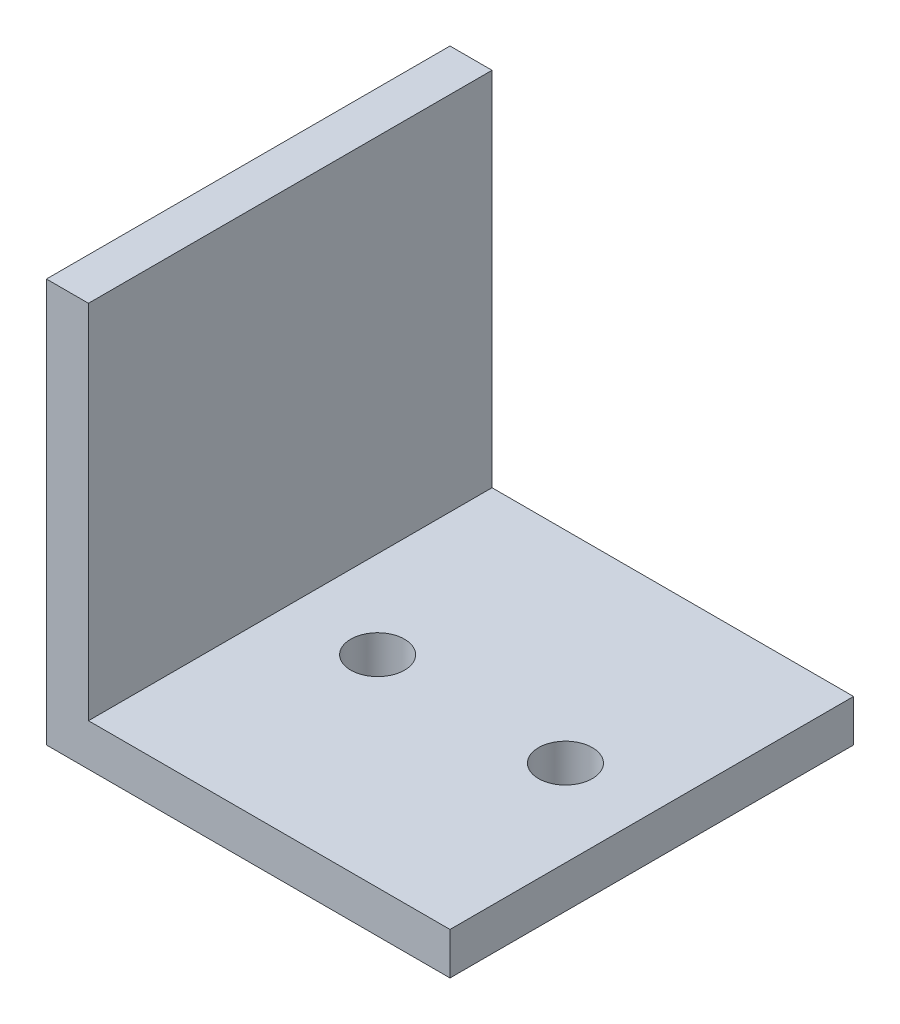
from build123d import *

# Parameters (mm, degrees)
EXTRUS_O_FINA1_DEPTH  = 30
ESBO_O2_R             = 2
CORTE_EXTRUS_O1_DEPTH = 30


with BuildPart() as part:
    # Esboço1 → Extrusão-Fina1 (new body)
    with BuildSketch(Plane.XY):
        Polygon((0, 0), (-30, 0), (-30, 30), (-26.875, 30), (-26.875, 3.125), (0, 3.125), align=None)
    extrude(amount=EXTRUS_O_FINA1_DEPTH)

    # Esboço2 → Corte-extrusão1 (cut)
    with BuildSketch(Plane(origin=(0, 3.125, 0), x_dir=(1, 0, 0), z_dir=(0, 1, 0))):
        with Locations(Location((-6.417692874, -15, 0), (0, 0, 180))):  # turned: the seam where the file's is
            Circle(ESBO_O2_R)
        with Locations(Location((-20.380879672, -15, 0), (0, 0, 180))):  # turned: the seam where the file's is
            Circle(ESBO_O2_R)
    extrude(amount=-CORTE_EXTRUS_O1_DEPTH, mode=Mode.SUBTRACT)


solid = part.part
